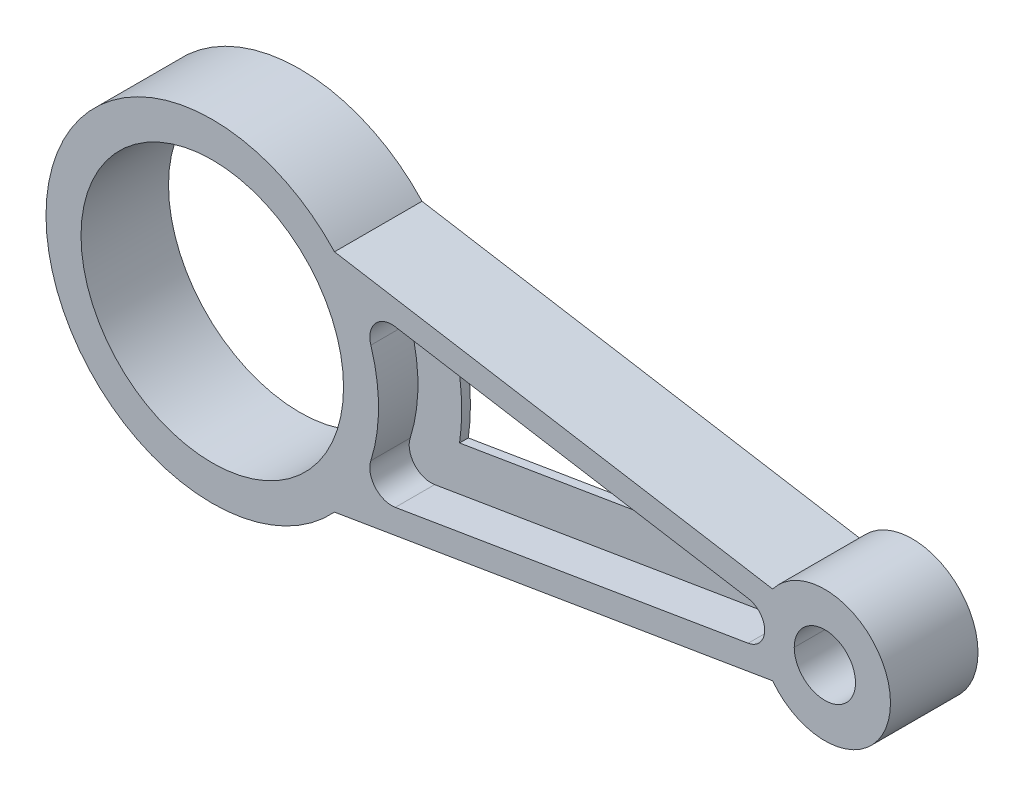
from build123d import *

# Parameters (mm, degrees)
SKETCH1_R           = 30
SKETCH1_R_2         = 7
BOSS_EXTRUDE1_DEPTH = 10
CUT_EXTRUDE1_DEPTH  = 9
CUT_EXTRUDE2_DEPTH  = 12


with BuildPart() as part:
    # Sketch1 → Boss-Extrude1 (new body, symmetric)
    with BuildSketch(Plane.XY):
        with BuildLine():
            Line((128.063755469, 9.084385863), (27.935473676, 25.760615491))
            ThreePointArc((27.935473676, 25.760615491), (-38, 0), (27.935473676, -25.760615491))
            Line((27.935473676, -25.760615491), (128.063755469, -9.084385863))
            ThreePointArc((128.063755469, -9.084385863), (155, 0), (128.063755469, 9.084385863))
        make_face()
        Circle(SKETCH1_R, mode=Mode.SUBTRACT)
        with Locations((140, 0)):
            Circle(SKETCH1_R_2, mode=Mode.SUBTRACT)
    extrude(amount=BOSS_EXTRUDE1_DEPTH, both=True)

    # Sketch2 → Cut-Extrude1 (cut)
    with BuildSketch(Plane.XY.offset(10)):
        with BuildLine():
            Line((41.828554558, 17.870982725), (122.478416149, 4.438857582))
            ThreePointArc((122.478416149, 4.438857582), (126.239130435, 0), (122.478416149, -4.438857582))
            Line((122.478416149, -4.438857582), (41.828554558, -17.870982725))
            ThreePointArc((41.828554558, -17.870982725), (37.231968897, -16.217361812), (36.238855523, -11.43439331))
            ThreePointArc((36.238855523, -11.43439331), (38, 0), (36.238855523, 11.43439331))
            ThreePointArc((36.238855523, 11.43439331), (37.231968897, 16.217361812), (41.828554558, 17.870982725))
        make_face()
    cut_extrude1 = extrude(amount=-CUT_EXTRUDE1_DEPTH, mode=Mode.SUBTRACT)

    # Mirror1: Cut-Extrude1 across plane
    add(cut_extrude1.mirror(Plane.XY), mode=Mode.SUBTRACT)

    # Sketch3 → Cut-Extrude2 (cut, through all)
    with BuildSketch(Plane.XY.offset(1)):
        with BuildLine():
            Line((47.517939236, -6.785679827), (88.260869565, 0))
            Line((88.260869565, 0), (47.517939236, 6.785679827))
            ThreePointArc((47.517939236, 6.785679827), (48, 0), (47.517939236, -6.785679827))
        make_face()
    extrude(amount=-CUT_EXTRUDE2_DEPTH, mode=Mode.SUBTRACT)


solid = part.part
